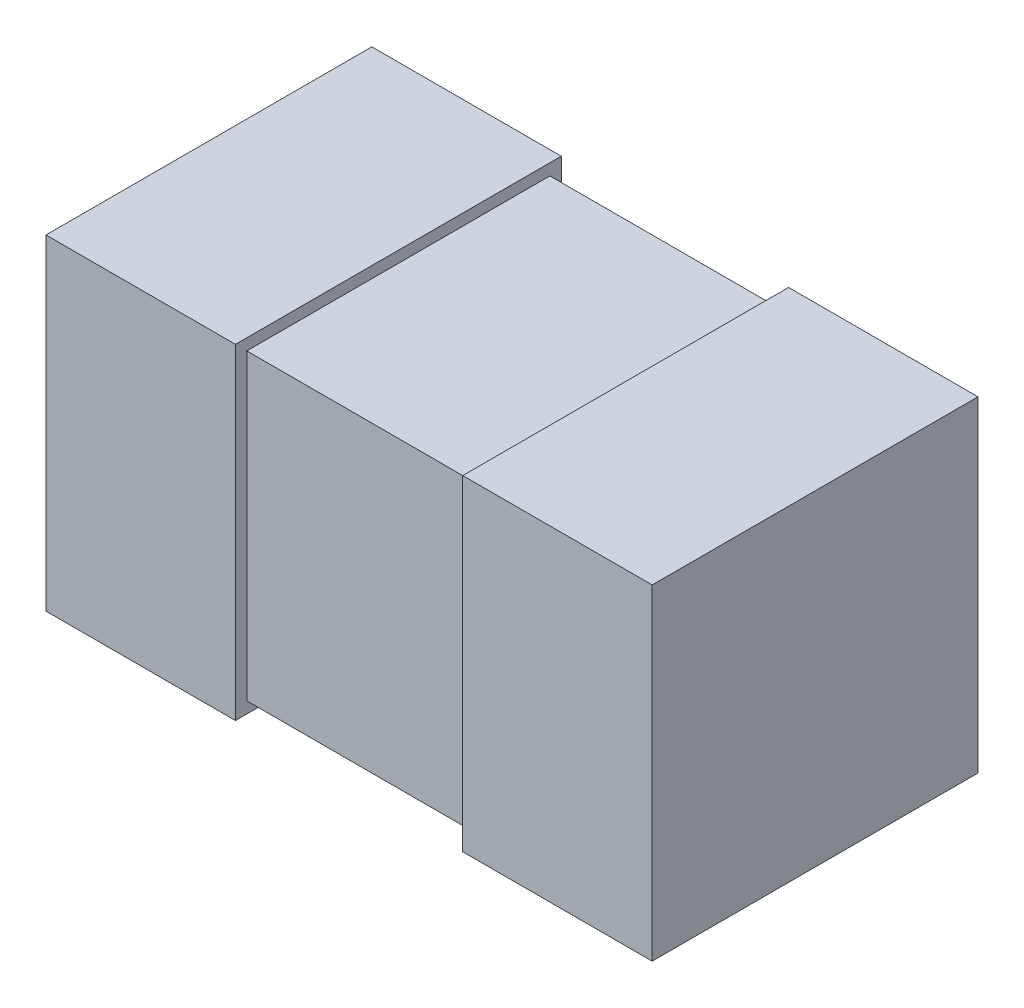
from build123d import *

# Parameters (mm, degrees)
SKETCH1_W           = 1.6
SKETCH1_H           = 0.8
EXTRUDE1_DEPTH      = 0.8
SKETCH2_W           = 0.5
SKETCH2_H           = 0.86
EXTRUDE2_DEPTH      = 0.43
EXTRUDE2_DEPTH_BACK = 0.43


with BuildPart() as part:
    # Sketch1 → Extrude1 (new body)
    with BuildSketch(Plane(origin=(0, 0, 0), x_dir=(1, 0, 0), z_dir=(0, 1, 0))):
        Rectangle(SKETCH1_W, SKETCH1_H)
    extrude(amount=EXTRUDE1_DEPTH)

    # Sketch2 → Extrude2 (add, two sides)
    with BuildSketch(Plane.XY) as extrude2_sk:
        with Locations((-0.55, 0.4)):
            Rectangle(SKETCH2_W, SKETCH2_H)
        with Locations((0.55, 0.4)):
            Rectangle(SKETCH2_W, SKETCH2_H)
    extrude(amount=EXTRUDE2_DEPTH)
    extrude(extrude2_sk.sketch, amount=-EXTRUDE2_DEPTH_BACK)


solid = part.part
